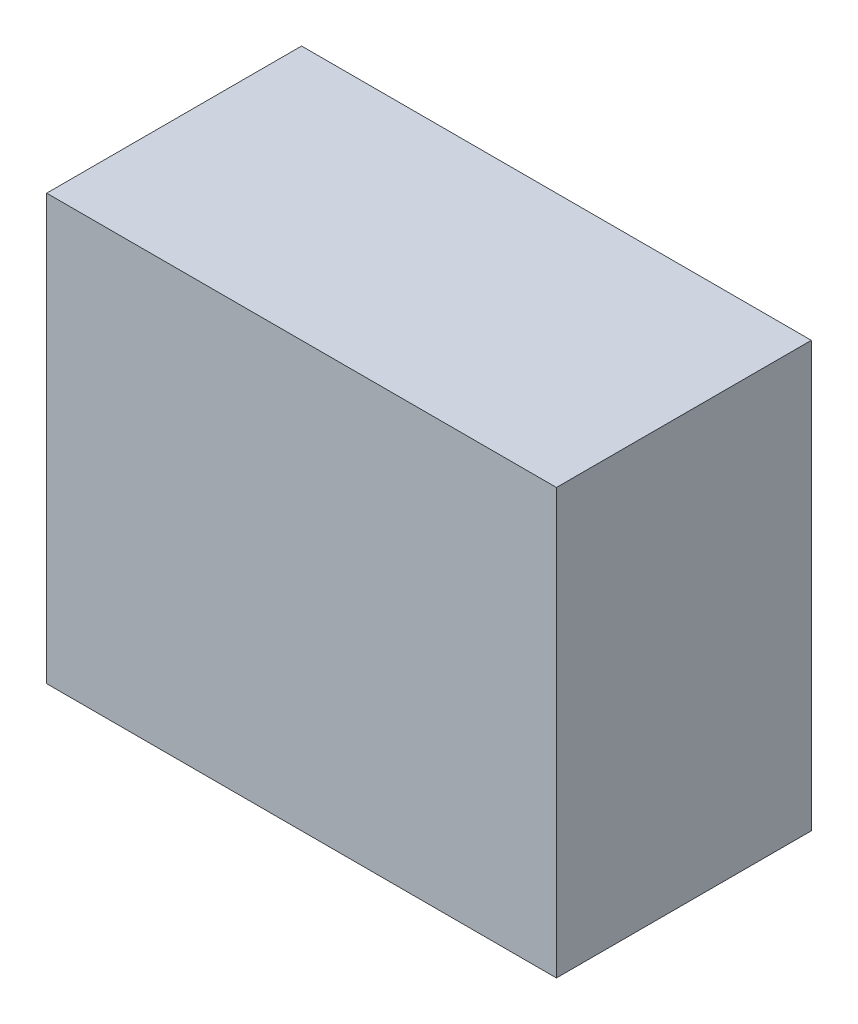
from build123d import *

# Parameters (mm, degrees)
SKETCH2_W           = 30
SKETCH2_H           = 25
BOSS_EXTRUDE1_DEPTH = 15


with BuildPart() as part:
    # Sketch2 → Boss-Extrude1 (new body)
    with BuildSketch(Plane.XY):
        Rectangle(SKETCH2_W, SKETCH2_H)
    extrude(amount=BOSS_EXTRUDE1_DEPTH)


solid = part.part
